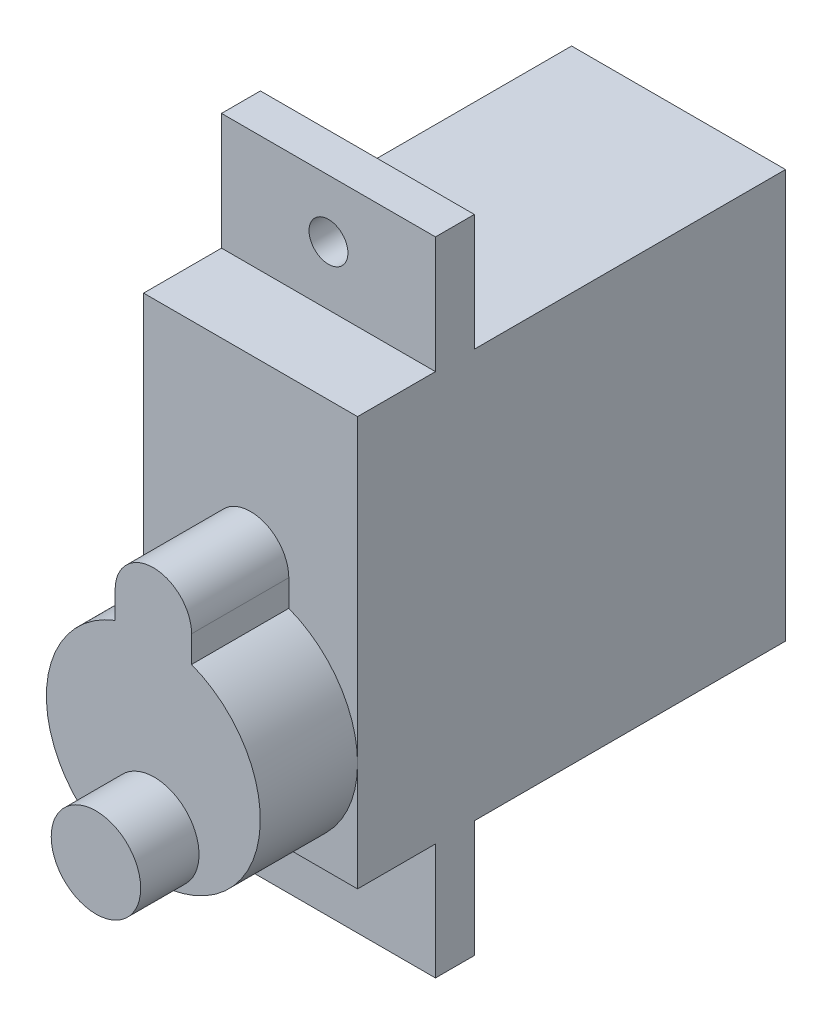
from build123d import *

# Parameters (mm, degrees)
CROQUIS1_W              = 11
CROQUIS1_H              = 33
SALIENTE_EXTRUIR1_DEPTH = 33
CROQUIS2_W              = 11
CROQUIS2_H              = 17
CORTAR_EXTRUIR1_DEPTH   = 6
CORTAR_EXTRUIR2_REACH   = 13
SALIENTE_EXTRUIR4_DEPTH = 5
CROQUIS7_R              = 2.3
SALIENTE_EXTRUIR5_DEPTH = 3
CROQUIS8_R              = 1
CORTAR_EXTRUIR4_DEPTH   = 3
CROQUIS9_W              = 1
CROQUIS9_H              = 21
CORTAR_EXTRUIR5_DEPTH   = 20


with BuildPart() as part:
    # Croquis1 → Saliente-Extruir1 (new body)
    with BuildSketch(Plane.XY):
        Rectangle(CROQUIS1_W, CROQUIS1_H)
    extrude(amount=SALIENTE_EXTRUIR1_DEPTH)

    # Croquis2 → Cortar-Extruir1 (cut)
    with BuildSketch(Plane.XZ.offset(16.5)):
        with Locations((0, 8.5)):
            Rectangle(CROQUIS2_W, CROQUIS2_H)
    cortar_extruir1 = extrude(amount=-CORTAR_EXTRUIR1_DEPTH, mode=Mode.SUBTRACT)

    # Simetría1: Cortar-Extruir1 across plane
    add(cortar_extruir1.mirror(Plane.ZX), mode=Mode.SUBTRACT)

    # Croquis3 → Cortar-Extruir2 (cut, up to next)
    with BuildSketch(Plane(origin=(5.5, 0, 0), x_dir=(0, 0, -1), z_dir=(1, 0, 0)), mode=Mode.PRIVATE) as cortar_extruir2_sk1:
        Polygon((-19, -16.5), (-19, -10.530920557), (-23.005061079, -10.530920557), (-23.005061079, 10.5), (-19, 10.5), (-19, 16.5), (-33, 16.5), (-33, -16.5), align=None)
    cortar_extruir2_tool1 = extrude(cortar_extruir2_sk1.sketch, amount=-CORTAR_EXTRUIR2_REACH, mode=Mode.PRIVATE) & part.part
    add(cortar_extruir2_tool1.solids().sort_by_distance((5.5, 0.003447, 27.11427))[0], mode=Mode.SUBTRACT)

    # Croquis6 → Saliente-Extruir4 (add)
    with BuildSketch(Plane.XY.offset(23.005061079)):
        with BuildLine():
            Line((-1.964593249, 1.559922557), (-1.964593249, 0.194840348))
            ThreePointArc((-1.964593249, 0.194840348), (0, -10.442315807), (1.964593249, 0.194840348))
            Line((1.964593249, 0.194840348), (1.964593249, 1.559922557))
            ThreePointArc((1.964593249, 1.559922557), (0, 3.524515805), (-1.964593249, 1.559922557))
        make_face()
    extrude(amount=SALIENTE_EXTRUIR4_DEPTH)

    # Croquis7 → Saliente-Extruir5 (add)
    with BuildSketch(Plane.XY.offset(28.005061079)):
        with Locations((0.048442296, -8.079125274)):
            Circle(CROQUIS7_R)
    extrude(amount=SALIENTE_EXTRUIR5_DEPTH)

    # Croquis8 → Cortar-Extruir4 (cut)
    with BuildSketch(Plane.XY.offset(19)):
        with Locations((0, -13.530920557)):
            Circle(CROQUIS8_R)
        with Locations((0, 13.530920557)):
            Circle(CROQUIS8_R)
    extrude(amount=-CORTAR_EXTRUIR4_DEPTH, mode=Mode.SUBTRACT)

    # Croquis9 → Cortar-Extruir5 (cut)
    with BuildSketch(Plane(origin=(5.5, 0, 0), x_dir=(0, 0, -1), z_dir=(1, 0, 0))):
        with Locations((-0.5, 0)):
            Rectangle(CROQUIS9_W, CROQUIS9_H)
    extrude(amount=-CORTAR_EXTRUIR5_DEPTH, mode=Mode.SUBTRACT)


solid = part.part
